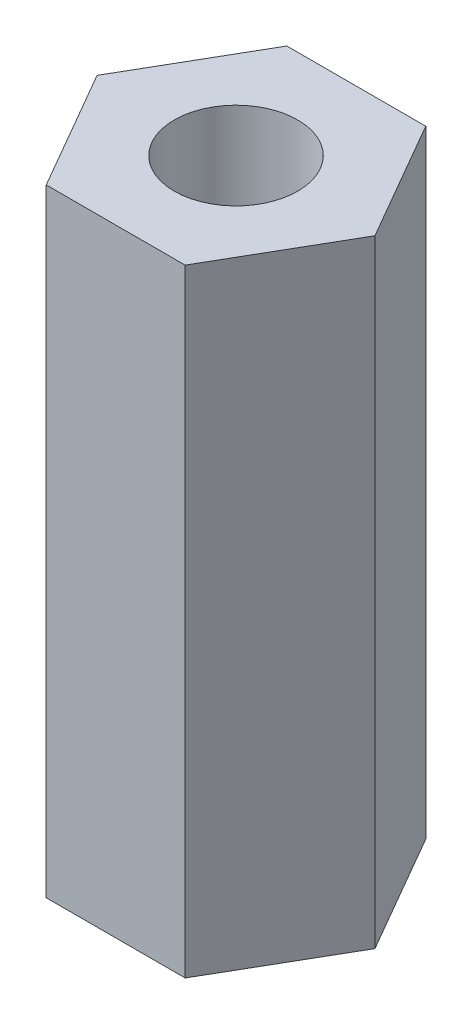
from build123d import *

# Parameters (mm, degrees)
SKETCH1_R           = 1
BOSS_EXTRUDE1_DEPTH = 10


with BuildPart() as part:
    # Sketch1 → Boss-Extrude1 (new body)
    with BuildSketch(Plane(origin=(0, 0, 0), x_dir=(1, 0, 0), z_dir=(0, 1, 0))):
        Polygon((2.25, 0), (1.125, 1.948557159), (-1.125, 1.948557159), (-2.25, 0), (-1.125, -1.948557159), (1.125, -1.948557159), align=None)
        Circle(SKETCH1_R, mode=Mode.SUBTRACT)
    extrude(amount=BOSS_EXTRUDE1_DEPTH)


solid = part.part
